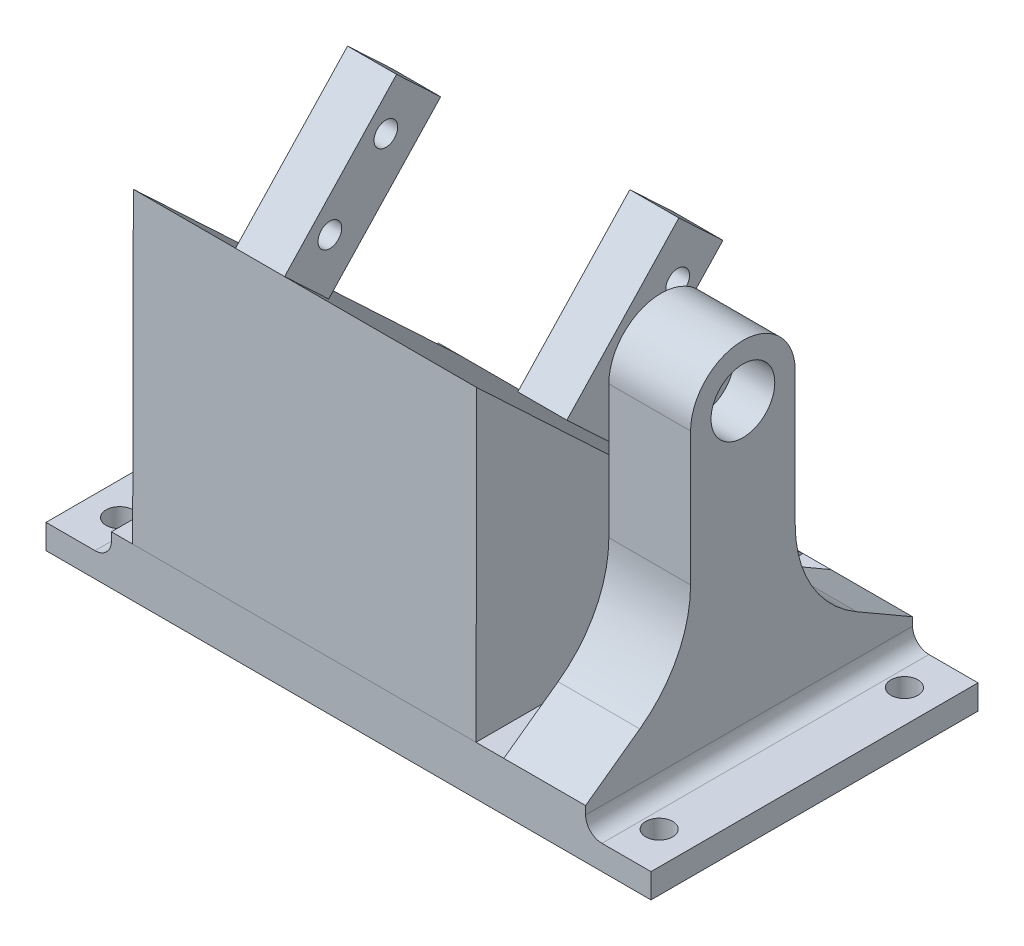
from build123d import *

# Parameters (mm, degrees)
SKETCH1_W              = 58
SKETCH1_H              = 40
BOSS_EXTRUDE1_DEPTH    = 6
BOSS_EXTRUDE3_START    = -2.6
BOSS_EXTRUDE3_DEPTH    = 42
SKETCH6_W              = 6
SKETCH6_H              = 7.4
BOSS_EXTRUDE4_DEPTH    = 20
BOSS_EXTRUDE5_DEPTH    = 10
M2_5_CLEARANCE_SLOT1_D = 2.9
SKETCH11_R             = 1.75
CUT_EXTRUDE1_DEPTH     = 10
SKETCH12_W             = 8
SKETCH12_H             = 40
SKETCH12_R             = 1.65
BOSS_EXTRUDE6_DEPTH    = 3
FILLET1_R              = 2
SKETCH8_R              = 3.9
CUT_EXTRUDE2_DEPTH     = 5


with BuildPart() as part:
    # Sketch1 → Boss-Extrude1 (new body)
    with BuildSketch(Plane(origin=(0, 0, 0), x_dir=(1, 0, 0), z_dir=(0, 1, 0))):
        Rectangle(SKETCH1_W, SKETCH1_H)
    extrude(amount=BOSS_EXTRUDE1_DEPTH)

    # Sketch4 → Boss-Extrude3 (add)
    with BuildSketch(Plane.ZY.offset(29).offset(BOSS_EXTRUDE3_START)):
        Polygon((-20, 6), (19.918609503, 43.543902506), (20, 6), align=None)
    extrude(amount=-BOSS_EXTRUDE3_DEPTH)

    # Sketch6 → Boss-Extrude4 (add)
    with BuildSketch(Plane(origin=(0, 13.164986139, -12.38181796), x_dir=(1, 0, 0), z_dir=(0, 0.728441779, -0.68510771))):
        with Locations((-10.9, -40.641810675)):
            Rectangle(SKETCH6_W, SKETCH6_H)
        with Locations((-10.9, 6.758189325)):
            Rectangle(SKETCH6_W, SKETCH6_H)
    extrude(amount=BOSS_EXTRUDE4_DEPTH)

    # Sketch7 → Boss-Extrude5 (add)
    with BuildSketch(Plane(origin=(29, 0, 0), x_dir=(0, 0, -1), z_dir=(1, 0, 0))):
        with BuildLine():
            Line((-20, 6), (-13.364634961, 10.800412746))
            ThreePointArc((-13.364634961, 10.800412746), (-8.798657798, 16.130102837), (-7.156866334, 22.953464523))
            Line((-7.156866334, 22.953464523), (-7.156866334, 39.25))
            ThreePointArc((-7.156866334, 39.25), (-0.756866334, 45.65), (5.643133666, 39.25))
            Line((5.643133666, 39.25), (5.643133666, 22.953464523))
            ThreePointArc((5.643133666, 22.953464523), (7.651002835, 15.456496038), (13.137071863, 9.966585137))
            Line((13.137071863, 9.966585137), (20, 6))
            Line((20, 6), (-20, 6))
        make_face()
    extrude(amount=-BOSS_EXTRUDE5_DEPTH)

    # M2.5 Clearance Slot1 (through all)
    with Locations(Plane(origin=(-16.9, -75.052586312, -128.704072023), x_dir=(0, -0.380749805, 0.924678098), z_dir=(-1, 0, 0))):
        with Locations((57.189532403, 125.168887287), (66.298114004, 121.041691966), (77.412789478, 169.800937131), (86.521371079, 165.67374181)):
            Hole(M2_5_CLEARANCE_SLOT1_D / 2)

    # Sketch11 → Cut-Extrude1 (cut)
    with BuildSketch(Plane(origin=(29, 0, 0), x_dir=(0, 0, -1), z_dir=(1, 0, 0))):
        with Locations((-0.756866334, 39.25)):
            Circle(SKETCH11_R)
    extrude(amount=-CUT_EXTRUDE1_DEPTH, mode=Mode.SUBTRACT)

    # Sketch12 → Boss-Extrude6 (add)
    with BuildSketch(Plane(origin=(0, 0, 0), x_dir=(1, 0, 0), z_dir=(0, 1, 0))):
        with Locations((33, 0)):
            Rectangle(SKETCH12_W, SKETCH12_H)
        with Locations((33, -15)):
            Circle(SKETCH12_R, mode=Mode.SUBTRACT)
        with Locations((33, 15)):
            Circle(SKETCH12_R, mode=Mode.SUBTRACT)
        with Locations((-33, 0)):
            Rectangle(SKETCH12_W, SKETCH12_H)
        with Locations((-33, 15)):
            Circle(SKETCH12_R, mode=Mode.SUBTRACT)
        with Locations((-33, -15)):
            Circle(SKETCH12_R, mode=Mode.SUBTRACT)
    extrude(amount=BOSS_EXTRUDE6_DEPTH)

    # Fillet1
    fillet1_edges = [part.edges().sort_by_distance(p)[0] for p in [
        (29, 3, 0),
        (-29, 3, 0),
    ]]
    fillet(fillet1_edges, radius=FILLET1_R)

    # Sketch8 → Cut-Extrude2 (cut)
    with BuildSketch(Plane(origin=(29, 0, 0), x_dir=(0, 0, -1), z_dir=(1, 0, 0))):
        with Locations((-0.756866334, 39.25)):
            Circle(SKETCH8_R)
    extrude(amount=-CUT_EXTRUDE2_DEPTH, mode=Mode.SUBTRACT)


solid = part.part
